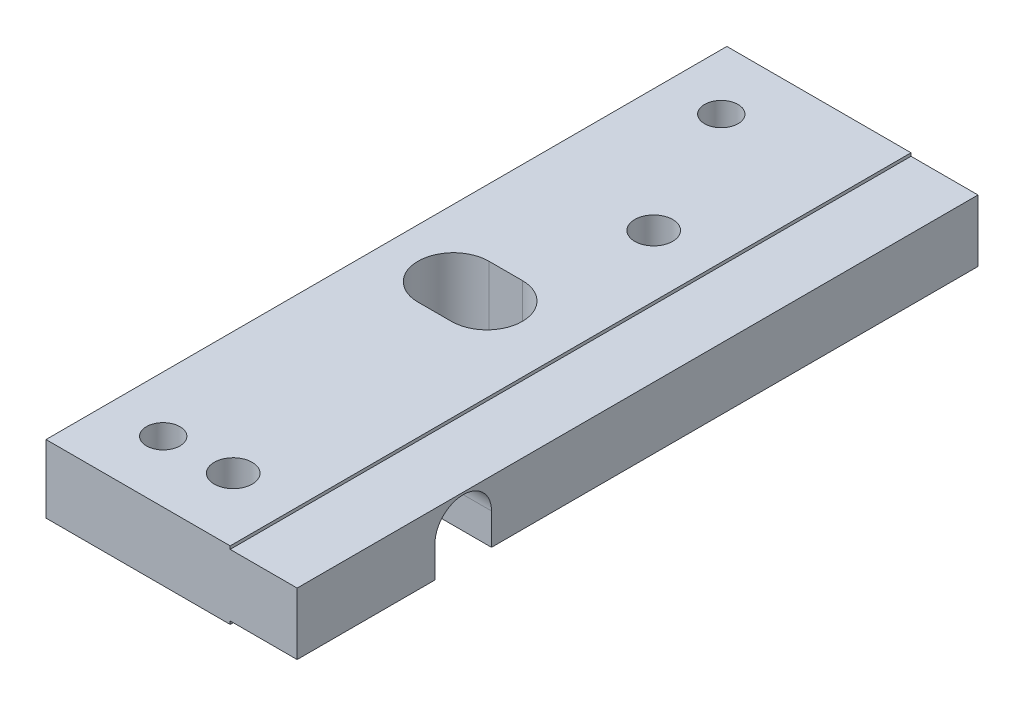
from build123d import *

# Parameters (mm, degrees)
SKETCH1_W                                        = 61
SKETCH1_H                                        = 6.1
BOSS_EXTRUDE1_DEPTH                              = 22.5
SKETCH2_OUTSIDE_W                                = 76.06
SKETCH2_OUTSIDE_H                                = 21.16
SKETCH2_OUTSIDE_W_2                              = 61
SKETCH2_OUTSIDE_H_2                              = 5.55
CUT_EXTRUDE1_DEPTH                               = 6
CUT_EXTRUDE3_DEPTH                               = 23.5
CUT_EXTRUDE4_DEPTH                               = 7.1
SKETCH7_R                                        = 1.5
CUT_EXTRUDE5_DEPTH                               = 7.1
CBORE_FOR_M3_PAN_HEAD_MACHINE_SCREW2_D           = 3.4
CBORE_FOR_M3_PAN_HEAD_MACHINE_SCREW2_CBORE_D     = 6.5
CBORE_FOR_M3_PAN_HEAD_MACHINE_SCREW2_CBORE_DEPTH = 2.2


with BuildPart() as part:
    # Sketch1 → Boss-Extrude1 (new body)
    with BuildSketch(Plane(origin=(0, 0, 0), x_dir=(0, 0, -1), z_dir=(1, 0, 0))):
        with Locations((30.5, 0)):
            Rectangle(SKETCH1_W, SKETCH1_H)
    extrude(amount=BOSS_EXTRUDE1_DEPTH)

    # Sketch2 outside → Cut-Extrude1 (cut)
    with BuildSketch(Plane(origin=(22.5, 0, 0), x_dir=(0, 0, -1), z_dir=(1, 0, 0))):
        with Locations((30.5, 0)):
            Rectangle(SKETCH2_OUTSIDE_W, SKETCH2_OUTSIDE_H)
        with Locations((30.5, 0)):
            Rectangle(SKETCH2_OUTSIDE_W_2, SKETCH2_OUTSIDE_H_2, mode=Mode.SUBTRACT)
    extrude(amount=-CUT_EXTRUDE1_DEPTH, mode=Mode.SUBTRACT)

    # Sketch5 → Cut-Extrude3 (cut, through all)
    with BuildSketch(Plane.ZY):
        with BuildLine():
            Line((-12.3486, 0.0496), (-12.3486, -3.05))
            Line((-12.3486, -3.05), (-17.4134, -3.05))
            Line((-17.4134, -3.05), (-17.4134, 0.0496))
            ThreePointArc((-17.4134, 0.0496), (-14.881, 2.582), (-12.3486, 0.0496))
        make_face()
    extrude(amount=-CUT_EXTRUDE3_DEPTH, mode=Mode.SUBTRACT)

    # Sketch6 → Cut-Extrude4 (cut, through all)
    with BuildSketch(Plane(origin=(0, 3.05, 0), x_dir=(1, 0, 0), z_dir=(0, 1, 0))):
        with BuildLine():
            Line((9, 27.325), (6, 27.325))
            ThreePointArc((6, 27.325), (2.825, 30.5), (6, 33.675))
            Line((6, 33.675), (9, 33.675))
            ThreePointArc((9, 33.675), (12.175, 30.5), (9, 27.325))
        make_face()
    extrude(amount=-CUT_EXTRUDE4_DEPTH, mode=Mode.SUBTRACT)

    # Sketch7 → Cut-Extrude5 (cut, through all)
    with BuildSketch(Plane(origin=(0, 3.05, 0), x_dir=(1, 0, 0), z_dir=(0, 1, 0))):
        with Locations(Location((5, 55.5, 0), (0, 0, 270))):  # turned: the seam where the file's is
            Circle(SKETCH7_R)
        with Locations(Location((5, 5.5, 0), (0, 0, 270))):  # turned: the seam where the file's is
            Circle(SKETCH7_R)
    extrude(amount=-CUT_EXTRUDE5_DEPTH, mode=Mode.SUBTRACT)

    # CBORE for M3 Pan Head Machine Screw2 (through all)
    with Locations(Plane(origin=(0, -3.05, 0), x_dir=(-1, 0, 0), z_dir=(0, -1, 0))):
        with Locations((-11, 5.772), (-11, 43.447)):
            CounterBoreHole(CBORE_FOR_M3_PAN_HEAD_MACHINE_SCREW2_D / 2, CBORE_FOR_M3_PAN_HEAD_MACHINE_SCREW2_CBORE_D / 2, CBORE_FOR_M3_PAN_HEAD_MACHINE_SCREW2_CBORE_DEPTH)


solid = part.part
